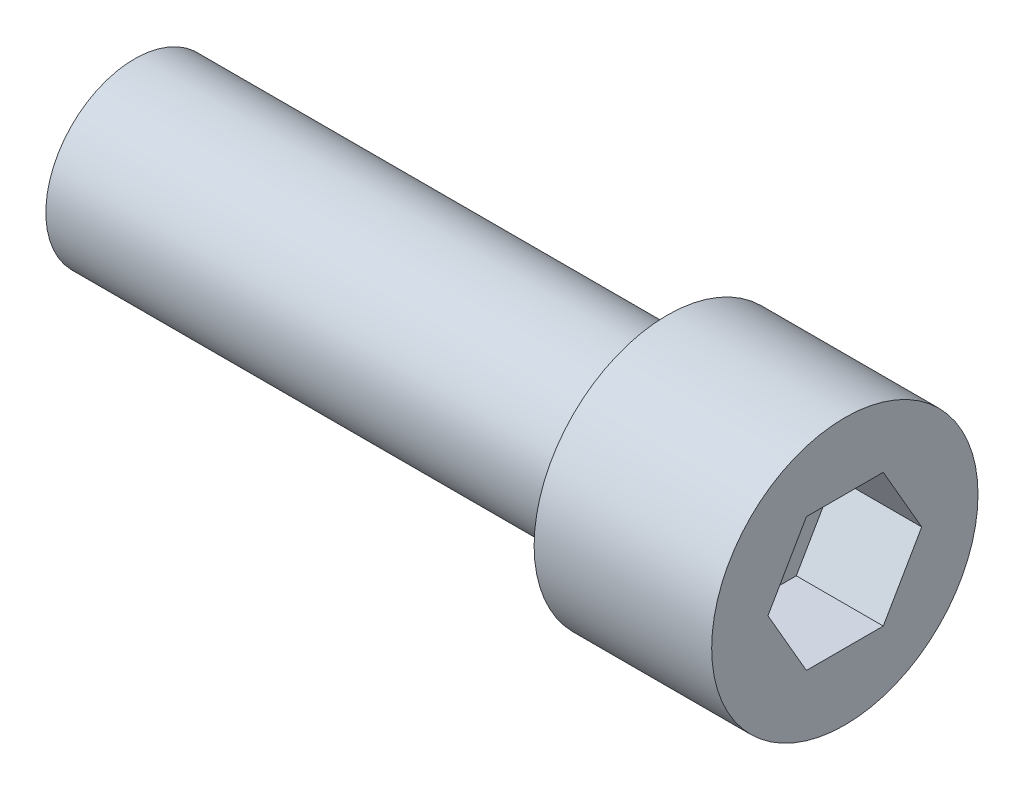
from build123d import *

# Parameters (mm, degrees)
SKETCH1_R           = 6.35
BOSS_EXTRUDE1_DEPTH = 38.1
SKETCH2_R           = 9.525
BOSS_EXTRUDE2_DEPTH = 12.7
CUT_EXTRUDE1_DEPTH  = 6.223


with BuildPart() as part:
    # Sketch1 → Boss-Extrude1 (new body)
    with BuildSketch(Plane(origin=(0, 0, 0), x_dir=(0, 0, -1), z_dir=(1, 0, 0))):
        Circle(SKETCH1_R)
    extrude(amount=-BOSS_EXTRUDE1_DEPTH)

    # Sketch2 → Boss-Extrude2 (add)
    with BuildSketch(Plane(origin=(0, 0, 0), x_dir=(0, 0, -1), z_dir=(1, 0, 0))):
        Circle(SKETCH2_R)
    extrude(amount=BOSS_EXTRUDE2_DEPTH)

    # Sketch3 → Cut-Extrude1 (cut)
    with BuildSketch(Plane(origin=(12.7, 0, 0), x_dir=(0, 0, -1), z_dir=(1, 0, 0))):
        Polygon((2.749630657, 4.7625), (-2.749630657, 4.7625), (-5.499261314, 0), (-2.749630657, -4.7625), (2.749630657, -4.7625), (5.499261314, 0), align=None)
    extrude(amount=-CUT_EXTRUDE1_DEPTH, mode=Mode.SUBTRACT)


solid = part.part
